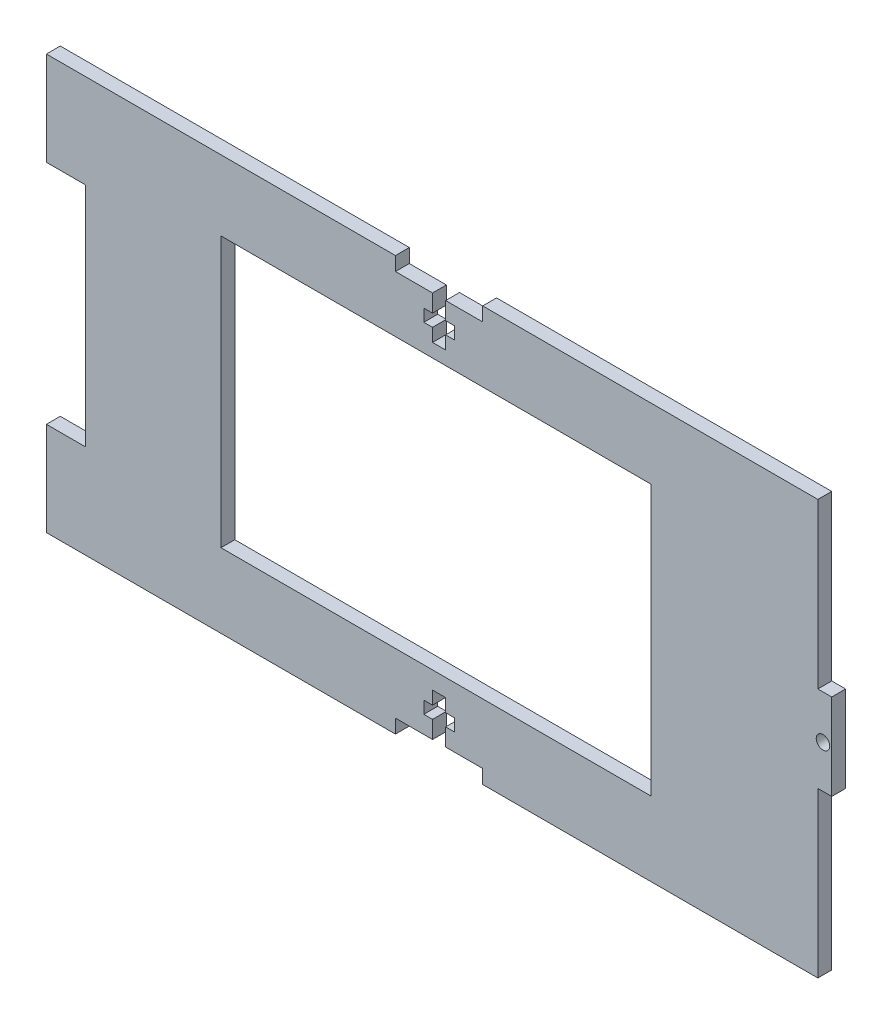
from build123d import *

# Parameters (mm, degrees)
SKETCH1_W               = 180
SKETCH1_H               = 95
BOSS_EXTRUDE1_DEPTH     = 3.18
CUT_EXTRUDE1_START      = -4.18
SKETCH2_W               = 3.18
SKETCH2_H               = 37.625
CUT_EXTRUDE1_DEPTH      = 5.18
SKETCH3_R               = 1.55
CUT_EXTRUDE2_DEPTH      = 1
CUT_EXTRUDE2_DEPTH_BACK = 4.18
CUT_EXTRUDE3_START      = -4.18
CUT_EXTRUDE3_DEPTH      = 5.18
SKETCH7_W               = 98.6
SKETCH7_H               = 61.9
CUT_EXTRUDE6_DEPTH      = 1
CUT_EXTRUDE6_DEPTH_BACK = 4.18
SKETCH8_W               = 9
SKETCH8_H               = 52
CUT_EXTRUDE7_DEPTH      = 1
CUT_EXTRUDE7_DEPTH_BACK = 4.18


with BuildPart() as part:
    # Sketch1 → Boss-Extrude1 (new body)
    with BuildSketch(Plane.XY):
        Rectangle(SKETCH1_W, SKETCH1_H)
    extrude(amount=BOSS_EXTRUDE1_DEPTH)

    # Sketch2 → Cut-Extrude1 (cut)
    with BuildSketch(Plane.XY.offset(3.18).offset(CUT_EXTRUDE1_START)):
        with Locations((88.41, 28.6875)):
            Rectangle(SKETCH2_W, SKETCH2_H)
    cut_extrude1 = extrude(amount=CUT_EXTRUDE1_DEPTH, mode=Mode.SUBTRACT)

    # Mirror1: Cut-Extrude1 across plane
    add(cut_extrude1.mirror(Plane.ZX), mode=Mode.SUBTRACT)

    # Sketch3 → Cut-Extrude2 (cut, two sides)
    with BuildSketch(Plane.XY.offset(3.18)) as cut_extrude2_sk:
        with Locations((88, -0.125)):
            Circle(SKETCH3_R)
    extrude(amount=CUT_EXTRUDE2_DEPTH, mode=Mode.SUBTRACT)
    extrude(cut_extrude2_sk.sketch, amount=-CUT_EXTRUDE2_DEPTH_BACK, mode=Mode.SUBTRACT)

    # Sketch4 → Cut-Extrude3 (cut)
    with BuildSketch(Plane.XY.offset(3.18).offset(CUT_EXTRUDE3_START)):
        Polygon((-10, -47.5), (10, -47.5), (10, -44.32), (1.5, -44.32), (1.5, -40.318812073), (3.5, -40.318812073), (3.5, -37.5), (1.5, -37.5), (1.5, -34.5), (-1.5, -34.5), (-1.5, -37.5), (-3.5, -37.5), (-3.5, -40.318812073), (-1.5, -40.318812073), (-1.5, -44.32), (-10, -44.32), align=None)
    cut_extrude3 = extrude(amount=CUT_EXTRUDE3_DEPTH, mode=Mode.SUBTRACT)

    # Mirror2: Cut-Extrude3 across plane
    add(cut_extrude3.mirror(Plane.ZX), mode=Mode.SUBTRACT)

    # Sketch7 → Cut-Extrude6 (cut, two sides)
    with BuildSketch(Plane(origin=(0, 0, 0), x_dir=(-1, 0, 0), z_dir=(0, 0, -1))) as cut_extrude6_sk:
        with Locations((0.7, 0.45)):
            Rectangle(SKETCH7_W, SKETCH7_H)
    extrude(amount=CUT_EXTRUDE6_DEPTH, mode=Mode.SUBTRACT)
    extrude(cut_extrude6_sk.sketch, amount=-CUT_EXTRUDE6_DEPTH_BACK, mode=Mode.SUBTRACT)

    # Sketch8 → Cut-Extrude7 (cut, two sides)
    with BuildSketch(Plane(origin=(0, 0, 0), x_dir=(-1, 0, 0), z_dir=(0, 0, -1))) as cut_extrude7_sk:
        with Locations((85.5, 0)):
            Rectangle(SKETCH8_W, SKETCH8_H)
    extrude(amount=CUT_EXTRUDE7_DEPTH, mode=Mode.SUBTRACT)
    extrude(cut_extrude7_sk.sketch, amount=-CUT_EXTRUDE7_DEPTH_BACK, mode=Mode.SUBTRACT)


solid = part.part
